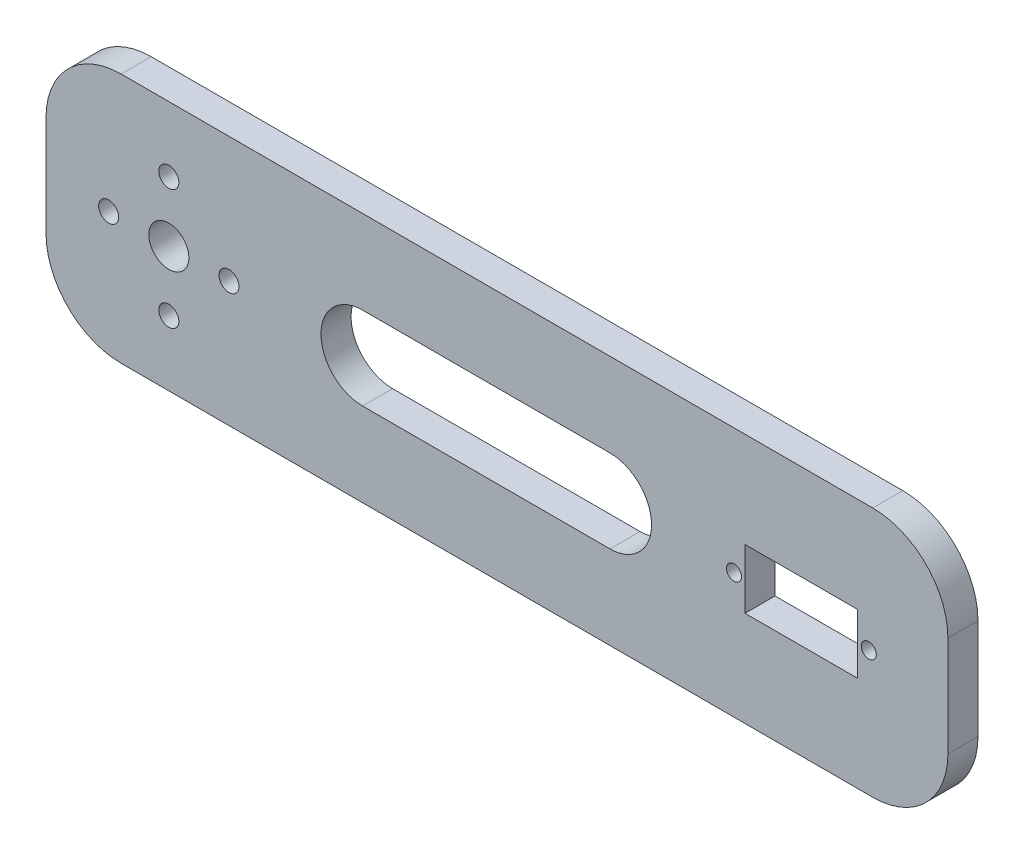
from build123d import *

# Parameters (mm, degrees)
SKETCH1_W           = 180
SKETCH1_H           = 50
BOSS_EXTRUDE1_DEPTH = 3
FILLET1_R           = 15
SKETCH3_R           = 4
SKETCH3_R_2         = 2
CUT_EXTRUDE1_DEPTH  = 8
SKETCH4_R           = 1.5
SKETCH4_W           = 22.5
SKETCH4_H           = 11.9
CUT_EXTRUDE2_DEPTH  = 10


with BuildPart() as part:
    # Sketch1 → Boss-Extrude1 (new body, symmetric)
    with BuildSketch(Plane.XY):
        with Locations((17.559596495, 0)):
            Rectangle(SKETCH1_W, SKETCH1_H)
    extrude(amount=BOSS_EXTRUDE1_DEPTH, both=True)

    # Fillet1
    fillet1_edges = [part.edges().sort_by_distance(p)[0] for p in [
        (107.559596495, -25, 0),
        (-72.440403505, -25, 0),
        (-72.440403505, 25, 0),
        (107.559596495, 25, 0),
    ]]
    fillet(fillet1_edges, radius=FILLET1_R)

    # Sketch3 → Cut-Extrude1 (cut)
    with BuildSketch(Plane.XY.offset(3)):
        with Locations((-47.926163707, 0)):
            Circle(SKETCH3_R)
        with Locations((-47.926163707, 12)):
            Circle(SKETCH3_R_2)
        with Locations((-47.926163707, -12)):
            Circle(SKETCH3_R_2)
        with Locations((-59.926163707, 0)):
            Circle(SKETCH3_R_2)
        with Locations((-35.926163707, 0)):
            Circle(SKETCH3_R_2)
    extrude(amount=-CUT_EXTRUDE1_DEPTH, mode=Mode.SUBTRACT)

    # Sketch4 → Cut-Extrude2 (cut)
    with BuildSketch(Plane.XY.offset(3)):
        with Locations((64.859596495, 0)):
            Circle(SKETCH4_R)
        with Locations((91.759596495, 0)):
            Circle(SKETCH4_R)
        with Locations((78.309596495, 0)):
            Rectangle(SKETCH4_W, SKETCH4_H)
        with BuildLine():
            Line((-9.269868987, 8.287867606), (40.115980257, 8.287867606))
            ThreePointArc((40.115980257, 8.287867606), (48.403847863, 0), (40.115980257, -8.287867606))
            Line((40.115980257, -8.287867606), (-9.269868987, -8.287867606))
            ThreePointArc((-9.269868987, -8.287867606), (-17.557736593, 0), (-9.269868987, 8.287867606))
        make_face()
    extrude(amount=-CUT_EXTRUDE2_DEPTH, mode=Mode.SUBTRACT)


solid = part.part
